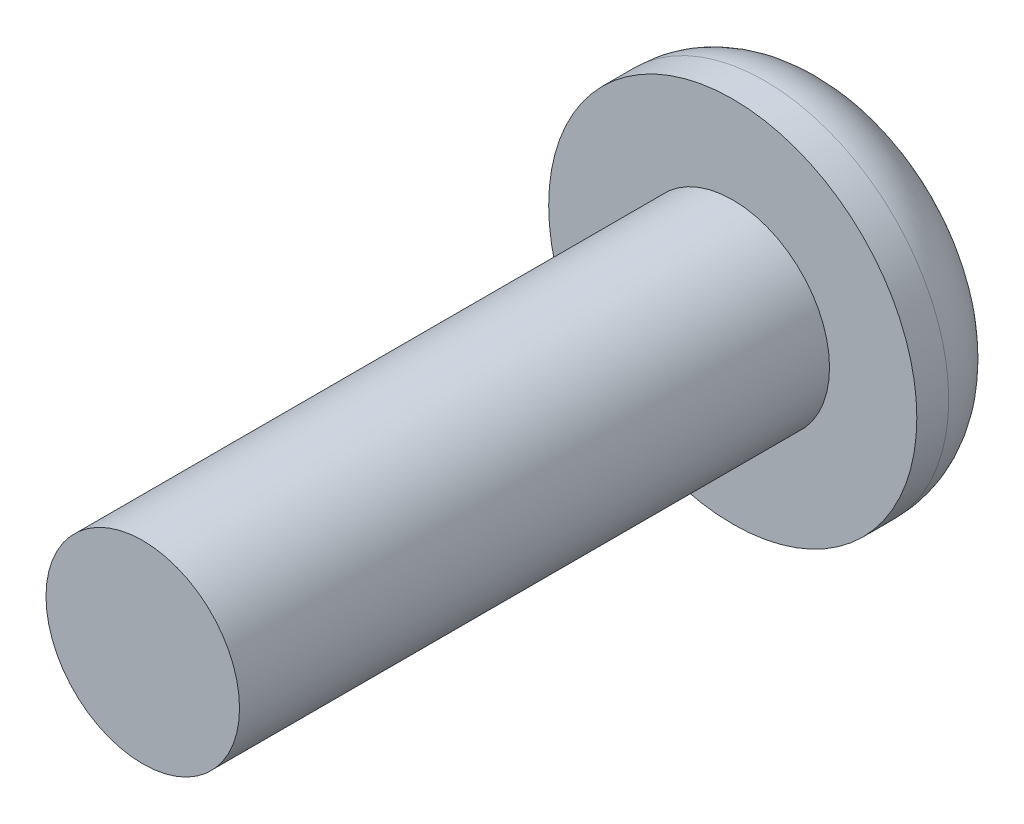
from build123d import *

# Parameters (mm, degrees)
SKETCH1_R      = 3.9624
EXTRUDE1_DEPTH = 2.2098
FILLET1_R      = 1.524
SKETCH2_R      = 2.0828
EXTRUDE2_DEPTH = 12.7
EXTRUDE3_DEPTH = 1.016


with BuildPart() as part:
    # Sketch1 → Extrude1 (new body)
    with BuildSketch(Plane.XY):
        Circle(SKETCH1_R)
    extrude(amount=EXTRUDE1_DEPTH)

    # Fillet1
    fillet1_edges = [part.edges().sort_by_distance(p)[0] for p in [
        (-3.9624, 0, 0),
    ]]
    fillet(fillet1_edges, radius=FILLET1_R)

    # Sketch2 → Extrude2 (add)
    with BuildSketch(Plane.XY.offset(2.2098)):
        Circle(SKETCH2_R)
    extrude(amount=EXTRUDE2_DEPTH)

    # Sketch3 → Extrude3 (cut)
    with BuildSketch(Plane(origin=(0, 0, 0), x_dir=(-1, 0, 0), z_dir=(0, 0, -1))):
        Polygon((0.709024608, 1.177879999), (-0.665561698, 1.202973322), (-1.374586306, 0.025093323), (-0.709024608, -1.177879999), (0.665561698, -1.202973322), (1.374586306, -0.025093323), align=None)
    extrude(amount=-EXTRUDE3_DEPTH, mode=Mode.SUBTRACT)


solid = part.part
